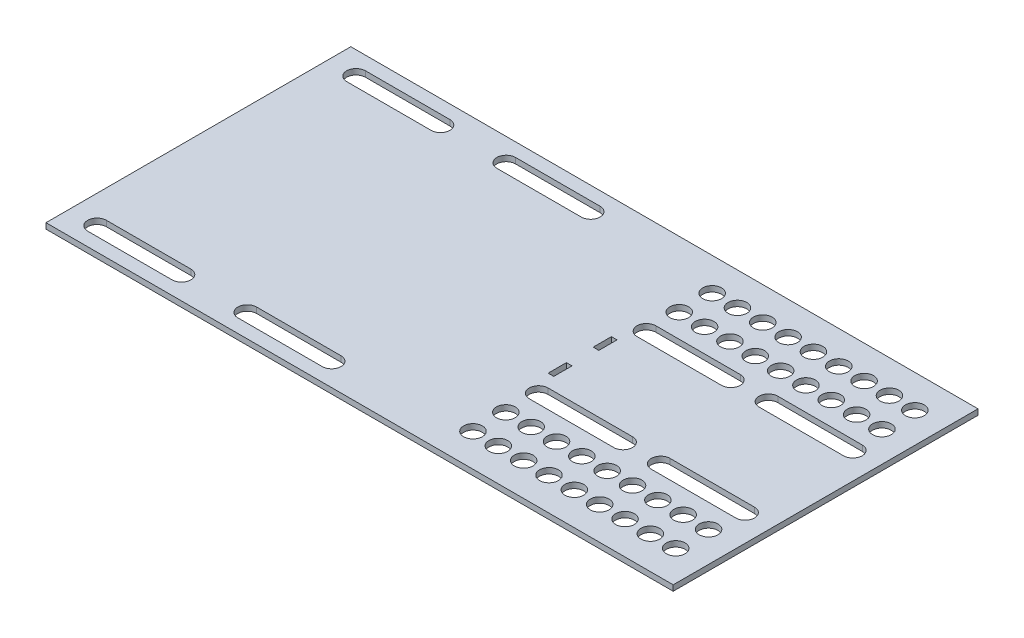
from build123d import *

# Parameters (mm, degrees)
SKETCH1_W           = 334.17
SKETCH1_H           = 162.4
BOSS_EXTRUDE1_DEPTH = 3
SKETCH2_R           = 5
CUT_EXTRUDE1_DEPTH  = 17
SKETCH3_W           = 3
SKETCH3_H           = 9.7
CUT_EXTRUDE3_DEPTH  = 45


with BuildPart() as part:
    # Sketch1 → Boss-Extrude1 (new body)
    with BuildSketch(Plane(origin=(0, 0, 0), x_dir=(1, 0, 0), z_dir=(0, 1, 0))):
        with Locations((167.085, -81.2)):
            Rectangle(SKETCH1_W, SKETCH1_H)
    extrude(amount=BOSS_EXTRUDE1_DEPTH)

    # Sketch2 → Cut-Extrude1 (cut)
    with BuildSketch(Plane(origin=(0, 0, 0), x_dir=(1, 0, 0), z_dir=(0, 1, 0))):
        with Locations((210, -17.5)):
            Circle(SKETCH2_R)
        with Locations((223.5, -17.5)):
            Circle(SKETCH2_R)
        with Locations((237, -17.5)):
            Circle(SKETCH2_R)
        with Locations((250.5, -17.5)):
            Circle(SKETCH2_R)
        with Locations((264, -17.5)):
            Circle(SKETCH2_R)
        with Locations((277.5, -17.5)):
            Circle(SKETCH2_R)
        with Locations((291, -17.5)):
            Circle(SKETCH2_R)
        with Locations((304.5, -17.5)):
            Circle(SKETCH2_R)
        with Locations((223.5, -35)):
            Circle(SKETCH2_R)
        with Locations((237, -35)):
            Circle(SKETCH2_R)
        with Locations((250.5, -35)):
            Circle(SKETCH2_R)
        with Locations((264, -35)):
            Circle(SKETCH2_R)
        with Locations((277.5, -35)):
            Circle(SKETCH2_R)
        with Locations((291, -35)):
            Circle(SKETCH2_R)
        with Locations((304.5, -35)):
            Circle(SKETCH2_R)
        with Locations((210, -35)):
            Circle(SKETCH2_R)
        with Locations((318, -17.5)):
            Circle(SKETCH2_R)
        with Locations((318, -35)):
            Circle(SKETCH2_R)
        with BuildLine():
            Line((210, -47.5), (255, -47.5))
            ThreePointArc((255, -47.5), (260, -52.5), (255, -57.5))
            Line((255, -57.5), (210, -57.5))
            ThreePointArc((210, -57.5), (205, -52.5), (210, -47.5))
        make_face()
        with BuildLine():
            Line((275, -57.5), (320, -57.5))
            ThreePointArc((320, -57.5), (325, -52.5), (320, -47.5))
            Line((320, -47.5), (275, -47.5))
            ThreePointArc((275, -47.5), (270, -52.5), (275, -57.5))
        make_face()
        with BuildLine():
            Line((15, -17.2), (60, -17.2))
            ThreePointArc((60, -17.2), (65, -12.2), (60, -7.2))
            Line((60, -7.2), (15, -7.2))
            ThreePointArc((15, -7.2), (10, -12.2), (15, -17.2))
        make_face()
        with BuildLine():
            Line((95, -7.2), (140, -7.2))
            ThreePointArc((140, -7.2), (145, -12.2), (140, -17.2))
            Line((140, -17.2), (95, -17.2))
            ThreePointArc((95, -17.2), (90, -12.2), (95, -7.2))
        make_face()
    cut_extrude1 = extrude(amount=CUT_EXTRUDE1_DEPTH, mode=Mode.SUBTRACT)

    # Mirror1: Cut-Extrude1 across plane
    add(cut_extrude1.mirror(Plane.XY.offset(81.2)), mode=Mode.SUBTRACT)

    # Sketch3 → Cut-Extrude3 (cut)
    with BuildSketch(Plane(origin=(0, 0, 0), x_dir=(1, 0, 0), z_dir=(0, 1, 0))):
        with Locations((204.7, -69.2)):
            Rectangle(SKETCH3_W, SKETCH3_H)
        with Locations((204.7, -93.2)):
            Rectangle(SKETCH3_W, SKETCH3_H)
    extrude(amount=CUT_EXTRUDE3_DEPTH, mode=Mode.SUBTRACT)


solid = part.part
